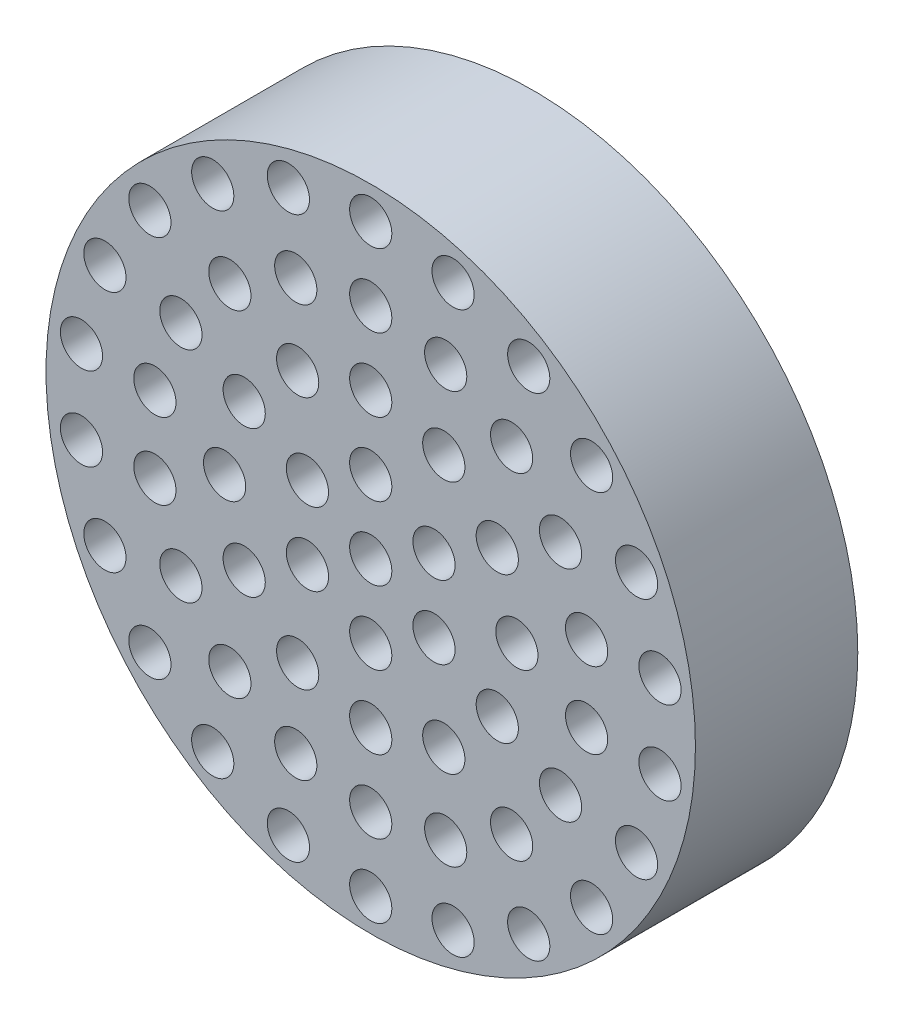
from build123d import *

# Parameters (mm, degrees)
ESQUISSE1_R             = 20
BOSS_EXTRU_1_DEPTH      = 10
ESQUISSE2_R             = 1.3
ENL_V_MAT_EXTRU_1_DEPTH = 10


with BuildPart() as part:
    # Esquisse1 → Boss.-Extru.1 (new body)
    with BuildSketch(Plane.XY):
        Circle(ESQUISSE1_R)
    extrude(amount=BOSS_EXTRU_1_DEPTH)

    # Esquisse2 → Enlèv. mat.-Extru.1 (cut)
    with BuildSketch(Plane.XY.offset(10)):
        with Locations((0, 4.5)):
            Circle(ESQUISSE2_R)
        with Locations((-3.897114317, 2.25)):
            Circle(ESQUISSE2_R)
        with Locations((-3.897114317, -2.25)):
            Circle(ESQUISSE2_R)
        with Locations((0, -4.5)):
            Circle(ESQUISSE2_R)
        with Locations((3.897114317, -2.25)):
            Circle(ESQUISSE2_R)
        with Locations((3.897114317, 2.25)):
            Circle(ESQUISSE2_R)
        Circle(ESQUISSE2_R)
        with Locations((0, 9)):
            Circle(ESQUISSE2_R)
        with Locations((4.5, 7.794228634)):
            Circle(ESQUISSE2_R)
        with Locations((7.794228634, 4.5)):
            Circle(ESQUISSE2_R)
        with Locations((9, 0)):
            Circle(ESQUISSE2_R)
        with Locations((7.794228634, -4.5)):
            Circle(ESQUISSE2_R)
        with Locations((4.5, -7.794228634)):
            Circle(ESQUISSE2_R)
        with Locations((0, -9)):
            Circle(ESQUISSE2_R)
        with Locations((-4.5, -7.794228634)):
            Circle(ESQUISSE2_R)
        with Locations((-7.794228634, -4.5)):
            Circle(ESQUISSE2_R)
        with Locations((-9, 0)):
            Circle(ESQUISSE2_R)
        with Locations((-7.794228634, 4.5)):
            Circle(ESQUISSE2_R)
        with Locations((-4.5, 7.794228634)):
            Circle(ESQUISSE2_R)
        with Locations((0, 13.5)):
            Circle(ESQUISSE2_R)
        with Locations((0, 18)):
            Circle(ESQUISSE2_R)
        with Locations((4.617271935, 12.685850381)):
            Circle(ESQUISSE2_R)
        with Locations((8.677632731, 10.341599982)):
            Circle(ESQUISSE2_R)
        with Locations((11.691342951, 6.75)):
            Circle(ESQUISSE2_R)
        with Locations((13.294904666, 2.344250399)):
            Circle(ESQUISSE2_R)
        with Locations((13.294904666, -2.344250399)):
            Circle(ESQUISSE2_R)
        with Locations((11.691342951, -6.75)):
            Circle(ESQUISSE2_R)
        with Locations((8.677632731, -10.341599982)):
            Circle(ESQUISSE2_R)
        with Locations((4.617271935, -12.685850381)):
            Circle(ESQUISSE2_R)
        with Locations((0, -13.5)):
            Circle(ESQUISSE2_R)
        with Locations((-4.617271935, -12.685850381)):
            Circle(ESQUISSE2_R)
        with Locations((-8.677632731, -10.341599982)):
            Circle(ESQUISSE2_R)
        with Locations((-11.691342951, -6.75)):
            Circle(ESQUISSE2_R)
        with Locations((-13.294904666, -2.344250399)):
            Circle(ESQUISSE2_R)
        with Locations((-13.294904666, 2.344250399)):
            Circle(ESQUISSE2_R)
        with Locations((-11.691342951, 6.75)):
            Circle(ESQUISSE2_R)
        with Locations((-8.677632731, 10.341599982)):
            Circle(ESQUISSE2_R)
        with Locations((-4.617271935, 12.685850381)):
            Circle(ESQUISSE2_R)
        with Locations((5.071186023, 17.270873525)):
            Circle(ESQUISSE2_R)
        with Locations((9.731534714, 15.142563591)):
            Circle(ESQUISSE2_R)
        with Locations((13.603492338, 11.787493211)):
            Circle(ESQUISSE2_R)
        with Locations((16.373375916, 7.477470234)):
            Circle(ESQUISSE2_R)
        with Locations((17.816785954, 2.561667089)):
            Circle(ESQUISSE2_R)
        with Locations((17.816785954, -2.561667089)):
            Circle(ESQUISSE2_R)
        with Locations((16.373375916, -7.477470234)):
            Circle(ESQUISSE2_R)
        with Locations((13.603492338, -11.787493211)):
            Circle(ESQUISSE2_R)
        with Locations((9.731534714, -15.142563591)):
            Circle(ESQUISSE2_R)
        with Locations((5.071186023, -17.270873525)):
            Circle(ESQUISSE2_R)
        with Locations((0, -18)):
            Circle(ESQUISSE2_R)
        with Locations((-5.071186023, -17.270873525)):
            Circle(ESQUISSE2_R)
        with Locations((-9.731534714, -15.142563591)):
            Circle(ESQUISSE2_R)
        with Locations((-13.603492338, -11.787493211)):
            Circle(ESQUISSE2_R)
        with Locations((-16.373375916, -7.477470234)):
            Circle(ESQUISSE2_R)
        with Locations((-17.816785954, -2.561667089)):
            Circle(ESQUISSE2_R)
        with Locations((-17.816785954, 2.561667089)):
            Circle(ESQUISSE2_R)
        with Locations((-16.373375916, 7.477470234)):
            Circle(ESQUISSE2_R)
        with Locations((-13.603492338, 11.787493211)):
            Circle(ESQUISSE2_R)
        with Locations((-9.731534714, 15.142563591)):
            Circle(ESQUISSE2_R)
        with Locations((-5.071186023, 17.270873525)):
            Circle(ESQUISSE2_R)
    extrude(amount=-ENL_V_MAT_EXTRU_1_DEPTH, mode=Mode.SUBTRACT)


solid = part.part
